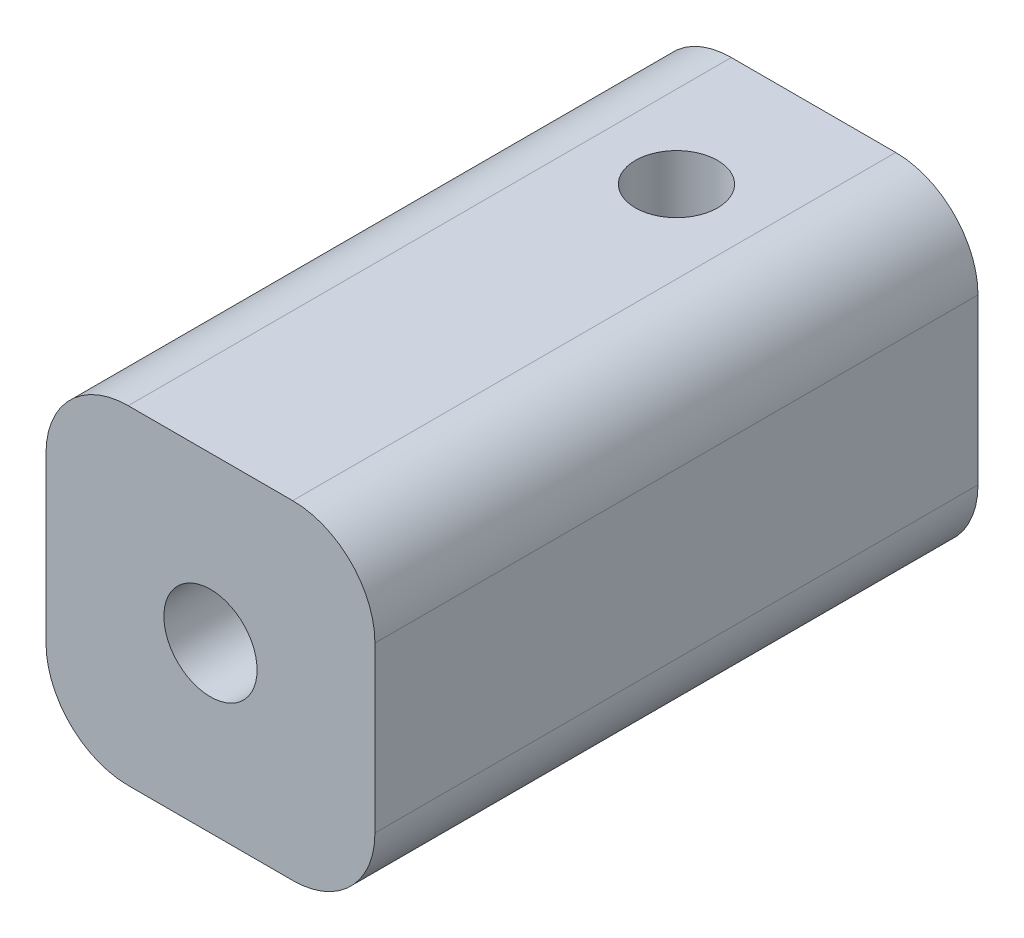
from build123d import *

# Parameters (mm, degrees)
ESBO_O1_W                  = 12
ESBO_O1_H                  = 12
ESBO_O1_R                  = 1.7
RESSALTO_EXTRUS_O1_DEPTH   = 22
ESBO_O2_R                  = 1.5
CORTE_EXTRUS_O1_DEPTH      = 7
CORTE_EXTRUS_O1_DEPTH_BACK = 10
FILETE2_R                  = 3
FILETE3_R                  = 3
FILETE4_R                  = 3
FILETE5_R                  = 3


with BuildPart() as part:
    # Esboço1 → Ressalto-extrusão1 (new body)
    with BuildSketch(Plane.XY):
        with Locations((13.471698113, -0.79245283)):
            Rectangle(ESBO_O1_W, ESBO_O1_H)
        with Locations((13.471698113, -0.79245283)):
            Circle(ESBO_O1_R, mode=Mode.SUBTRACT)
    extrude(amount=RESSALTO_EXTRUS_O1_DEPTH)

    # Esboço2 → Corte-extrusão1 (cut, two sides)
    with BuildSketch(Plane(origin=(0, 0, 0), x_dir=(1, 0, 0), z_dir=(0, 1, 0))) as corte_extrus_o1_sk:
        with Locations((13.471698113, -5)):
            Circle(ESBO_O2_R)
    extrude(amount=CORTE_EXTRUS_O1_DEPTH, mode=Mode.SUBTRACT)
    extrude(corte_extrus_o1_sk.sketch, amount=-CORTE_EXTRUS_O1_DEPTH_BACK, mode=Mode.SUBTRACT)

    # Filete2
    filete2_edges = [part.edges().sort_by_distance(p)[0] for p in [
        (7.471698113, 5.20754717, 11),
    ]]
    fillet(filete2_edges, radius=FILETE2_R)

    # Filete3
    filete3_edges = [part.edges().sort_by_distance(p)[0] for p in [
        (7.471698113, -6.79245283, 11),
    ]]
    fillet(filete3_edges, radius=FILETE3_R)

    # Filete4
    filete4_edges = [part.edges().sort_by_distance(p)[0] for p in [
        (19.471698113, -6.79245283, 11),
    ]]
    fillet(filete4_edges, radius=FILETE4_R)

    # Filete5
    filete5_edges = [part.edges().sort_by_distance(p)[0] for p in [
        (19.471698113, 5.20754717, 11),
    ]]
    fillet(filete5_edges, radius=FILETE5_R)


solid = part.part
